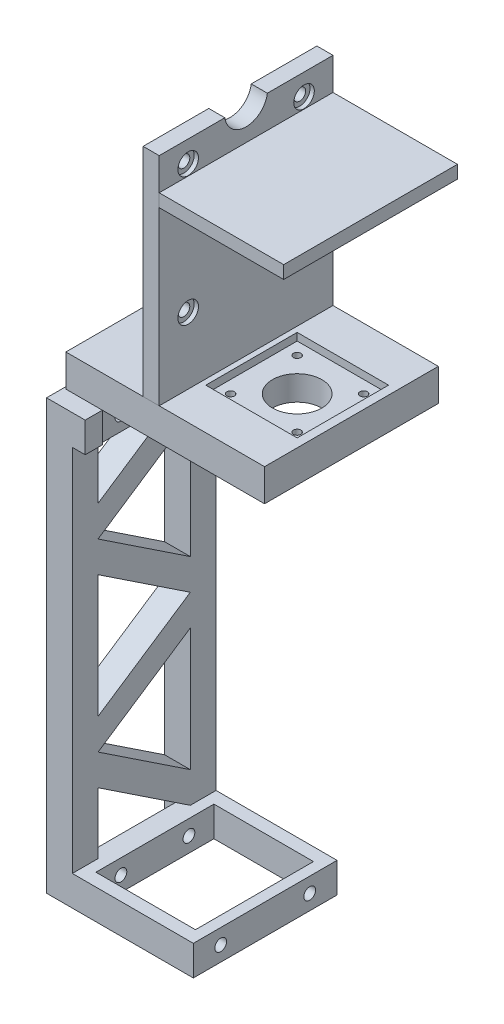
from build123d import *

# Parameters (mm, degrees)
SKETCH1_W            = 56.4
SKETCH1_H            = 67
SKETCH1_W_2          = 46.4
SKETCH1_H_2          = 55
BOSS_EXTRUDE1_DEPTH  = 14
SKETCH4_W            = 12
SKETCH4_H            = 12
BOSS_EXTRUDE2_DEPTH  = 200
SKETCH16_W           = 4.6
SKETCH16_H           = 14
BOSS_EXTRUDE11_DEPTH = 43
SKETCH5_W            = 5
SKETCH5_H            = 67
BOSS_EXTRUDE3_DEPTH  = 14
BOSS_EXTRUDE4_REACH  = 216.011
SKETCH2_R            = 2.75
CUT_EXTRUDE1_DEPTH   = 5
SKETCH3_R            = 2.75
CUT_EXTRUDE2_DEPTH   = 210.198972273
SKETCH7_R            = 2.75
CUT_EXTRUDE3_DEPTH   = 217.851100989
SKETCH8_W            = 8
SKETCH8_H            = 14
BOSS_EXTRUDE5_DEPTH  = 1
SKETCH9_W            = 92.6
SKETCH9_H            = 81
SKETCH9_W_2          = 6.786539707
BOSS_EXTRUDE6_DEPTH  = 15
SKETCH10_W           = 42.6
SKETCH10_H           = 42.6
CUT_EXTRUDE4_DEPTH   = 3.5
SKETCH11_R           = 1.75
SKETCH11_R_2         = 11.5
CUT_EXTRUDE5_DEPTH   = 11.5
CUT_EXTRUDE6_START   = 8.5
SKETCH11_5_R         = 3
SKETCH11_5_R_2       = 1.75
SKETCH11_5_R_3       = 11.5
CUT_EXTRUDE6_DEPTH   = 3
SKETCH13_R           = 2.75
BOSS_EXTRUDE7_DEPTH  = 5.5
BOSS_EXTRUDE10_START = -5.5
SKETCH13_3_R         = 4.8
BOSS_EXTRUDE10_DEPTH = 2
SKETCH15_W           = 81
SKETCH15_H           = 6
BOSS_EXTRUDE9_DEPTH  = 58


with BuildPart() as part:
    # Sketch1 → Boss-Extrude1 (new body)
    with BuildSketch(Plane(origin=(0, 0, 0), x_dir=(1, 0, 0), z_dir=(0, 1, 0))):
        Rectangle(SKETCH1_W, SKETCH1_H)
        Rectangle(SKETCH1_W_2, SKETCH1_H_2, mode=Mode.SUBTRACT)
    extrude(amount=BOSS_EXTRUDE1_DEPTH)

    # Sketch4 → Boss-Extrude2 (add)
    with BuildSketch(Plane(origin=(0, 0, 0), x_dir=(1, 0, 0), z_dir=(0, 1, 0))):
        with Locations((-34.2, -27.5)):
            Rectangle(SKETCH4_W, SKETCH4_H)
        with Locations((-34.2, 27.5)):
            Rectangle(SKETCH4_W, SKETCH4_H)
    extrude(amount=BOSS_EXTRUDE2_DEPTH)

    # Sketch16 → Boss-Extrude11 (add)
    with BuildSketch(Plane.XY.offset(-21.5)):
        with Locations((-30.5, 7)):
            Rectangle(SKETCH16_W, SKETCH16_H)
    extrude(amount=BOSS_EXTRUDE11_DEPTH)

    # Sketch5 → Boss-Extrude3 (add)
    with BuildSketch(Plane(origin=(0, 200, 0), x_dir=(1, 0, 0), z_dir=(0, 1, 0))):
        with Locations((-25.7, 0)):
            Rectangle(SKETCH5_W, SKETCH5_H)
    extrude(amount=-BOSS_EXTRUDE3_DEPTH)

    # Boss-Extrude4: up to this face of the body (flat: up to its plane)
    boss_extrude4_end = Plane(part.part.faces().sort_by_distance((-28.2, 100, 27.5))[0])
    # Sketch6 → Boss-Extrude4 (add, up to the picked face)
    with BuildSketch(Plane.ZY.offset(40.2), mode=Mode.PRIVATE) as boss_extrude4_sk1:
        Polygon((21.5, 157.410301507), (-21.5, 186), (-21.5, 171.589698493), (21.5, 143), align=None)
    boss_extrude4_tool1 = split(extrude(boss_extrude4_sk1.sketch, amount=-BOSS_EXTRUDE4_REACH, mode=Mode.PRIVATE), bisect_by=boss_extrude4_end, keep=Keep.BOTH, mode=Mode.PRIVATE)
    # Sketch6 → Boss-Extrude4 (add, up to the picked face)
    with BuildSketch(Plane.ZY.offset(40.2), mode=Mode.PRIVATE) as boss_extrude4_sk2:
        Polygon((21.5, 128.589698493), (21.5, 143), (-21.5, 114.410301507), (-21.5, 100), align=None)
    boss_extrude4_tool2 = split(extrude(boss_extrude4_sk2.sketch, amount=-BOSS_EXTRUDE4_REACH, mode=Mode.PRIVATE), bisect_by=boss_extrude4_end, keep=Keep.BOTH, mode=Mode.PRIVATE)
    # Sketch6 → Boss-Extrude4 (add, up to the picked face)
    with BuildSketch(Plane.ZY.offset(40.2), mode=Mode.PRIVATE) as boss_extrude4_sk3:
        Polygon((21.5, 71.410301507), (-21.5, 100), (-21.5, 85.589698493), (21.5, 57), align=None)
    boss_extrude4_tool3 = split(extrude(boss_extrude4_sk3.sketch, amount=-BOSS_EXTRUDE4_REACH, mode=Mode.PRIVATE), bisect_by=boss_extrude4_end, keep=Keep.BOTH, mode=Mode.PRIVATE)
    # Sketch6 → Boss-Extrude4 (add, up to the picked face)
    with BuildSketch(Plane.ZY.offset(40.2), mode=Mode.PRIVATE) as boss_extrude4_sk4:
        Polygon((21.5, 42.589698493), (21.5, 57), (-21.5, 28.410301507), (-21.5, 14), align=None)
    boss_extrude4_tool4 = split(extrude(boss_extrude4_sk4.sketch, amount=-BOSS_EXTRUDE4_REACH, mode=Mode.PRIVATE), bisect_by=boss_extrude4_end, keep=Keep.BOTH, mode=Mode.PRIVATE)
    add(boss_extrude4_tool1.solids().sort_by(Axis((-40.2, 164.5, 0), (1, 0, 0)))[0])
    add(boss_extrude4_tool2.solids().sort_by(Axis((-40.2, 121.5, 0), (1, 0, 0)))[0])
    add(boss_extrude4_tool3.solids().sort_by(Axis((-40.2, 78.5, 0), (1, 0, 0)))[0])
    add(boss_extrude4_tool4.solids().sort_by(Axis((-40.2, 35.5, 0), (1, 0, 0)))[0])

    # Sketch2 → Cut-Extrude1 (cut)
    with BuildSketch(Plane(origin=(28.2, 0, 0), x_dir=(0, 0, -1), z_dir=(1, 0, 0))):
        with Locations((-20.75, 7)):
            Circle(SKETCH2_R)
        with Locations((20.75, 7)):
            Circle(SKETCH2_R)
    extrude(amount=-CUT_EXTRUDE1_DEPTH, mode=Mode.SUBTRACT)

    # Sketch3 → Cut-Extrude2 (cut, through all)
    with BuildSketch(Plane(origin=(-23.2, 0, 0), x_dir=(0, 0, -1), z_dir=(1, 0, 0))):
        with Locations((15.85, 7)):
            Circle(SKETCH3_R)
        with Locations((-15.85, 7)):
            Circle(SKETCH3_R)
    extrude(amount=-CUT_EXTRUDE2_DEPTH, mode=Mode.SUBTRACT)

    # Sketch7 → Cut-Extrude3 (cut, through all)
    with BuildSketch(Plane(origin=(-23.2, 0, -32.7), x_dir=(0, 0, -1), z_dir=(1, 0, 0))):
        with Locations((-16.85, 193)):
            Circle(SKETCH7_R)
        with Locations((-48.55, 193)):
            Circle(SKETCH7_R)
    extrude(amount=-CUT_EXTRUDE3_DEPTH, mode=Mode.SUBTRACT)

    # Sketch8 → Boss-Extrude5 (add)
    with BuildSketch(Plane(origin=(-23.2, 0, 0), x_dir=(0, 0, -1), z_dir=(1, 0, 0))):
        with Locations((-29.5, 193)):
            Rectangle(SKETCH8_W, SKETCH8_H)
        with Locations((29.5, 193)):
            Rectangle(SKETCH8_W, SKETCH8_H)
    extrude(amount=BOSS_EXTRUDE5_DEPTH)


with BuildPart() as body_2:
    # Sketch9 → Boss-Extrude6 (new body)
    with BuildSketch(Plane(origin=(0, 215, 0), x_dir=(1, 0, 0), z_dir=(0, 1, 0))):
        with Locations((22.1, 0)):
            Rectangle(SKETCH9_W, SKETCH9_H)
        with Locations((-18.806730147, 0)):
            Rectangle(SKETCH9_W_2, SKETCH9_H)
    extrude(amount=BOSS_EXTRUDE6_DEPTH)

    # Sketch10 → Cut-Extrude4 (cut)
    with BuildSketch(Plane(origin=(0, 230, 0), x_dir=(1, 0, 0), z_dir=(0, 1, 0))):
        with Locations((43.1, 0)):
            Rectangle(SKETCH10_W, SKETCH10_H)
    extrude(amount=-CUT_EXTRUDE4_DEPTH, mode=Mode.SUBTRACT)

    # Sketch11 → Cut-Extrude5 (cut)
    with BuildSketch(Plane(origin=(0, 226.5, -221.5), x_dir=(1, 0, 0), z_dir=(0, -1, 0))):
        with Locations(Location((58.6, 237, 0), (0, 0, 90))):
            Circle(SKETCH11_R)
        with Locations(Location((27.6, 237, 0), (0, 0, 90))):
            Circle(SKETCH11_R)
        with Locations(Location((27.6, 206, 0), (0, 0, 90))):
            Circle(SKETCH11_R)
        with Locations(Location((58.6, 206, 0), (0, 0, 90))):
            Circle(SKETCH11_R)
        with Locations(Location((43.1, 221.5, 0), (0, 0, 90))):
            Circle(SKETCH11_R_2)
    extrude(amount=CUT_EXTRUDE5_DEPTH, mode=Mode.SUBTRACT)

    # Sketch11_5 → Cut-Extrude6 (cut)
    with BuildSketch(Plane(origin=(0, 226.5, -221.5), x_dir=(1, 0, 0), z_dir=(0, -1, 0)).offset(CUT_EXTRUDE6_START)):
        with Locations(Location((27.6, 237, 0), (0, 0, 90))):
            Circle(SKETCH11_5_R)
        with Locations(Location((27.6, 237, 0), (0, 0, 90))):
            Circle(SKETCH11_5_R_2, mode=Mode.SUBTRACT)
        with Locations(Location((58.6, 237, 0), (0, 0, 90))):
            Circle(SKETCH11_5_R)
        with Locations(Location((58.6, 237, 0), (0, 0, 90))):
            Circle(SKETCH11_5_R_2, mode=Mode.SUBTRACT)
        with Locations(Location((58.6, 206, 0), (0, 0, 90))):
            Circle(SKETCH11_5_R)
        with Locations(Location((58.6, 206, 0), (0, 0, 90))):
            Circle(SKETCH11_5_R_2, mode=Mode.SUBTRACT)
        with Locations(Location((27.6, 206, 0), (0, 0, 90))):
            Circle(SKETCH11_5_R)
        with Locations(Location((27.6, 206, 0), (0, 0, 90))):
            Circle(SKETCH11_5_R_2, mode=Mode.SUBTRACT)
        with Locations(Location((43.1, 221.5, 0), (0, 0, 90))):
            Circle(SKETCH11_5_R_3)
    extrude(amount=CUT_EXTRUDE6_DEPTH, mode=Mode.SUBTRACT)


with BuildPart() as body_3:
    # Sketch13 → Boss-Extrude7 (new body)
    with BuildSketch(Plane.ZY.offset(-11.8)):
        with BuildLine():
            Line((-9.905396324, 331), (-40.5, 331))
            Line((-40.5, 331), (-40.5, 230))
            Line((-40.5, 230), (40.5, 230))
            Line((40.5, 230), (40.5, 331))
            Line((40.5, 331), (9.905396324, 331))
            ThreePointArc((9.905396324, 331), (0, 322.372269531), (-9.905396324, 331))
        make_face()
        with Locations((-27, 261)):
            Circle(SKETCH13_R, mode=Mode.SUBTRACT)
        with Locations((27, 321)):
            Circle(SKETCH13_R, mode=Mode.SUBTRACT)
        with Locations((27, 261)):
            Circle(SKETCH13_R, mode=Mode.SUBTRACT)
        with Locations((-27, 321)):
            Circle(SKETCH13_R, mode=Mode.SUBTRACT)
    extrude(amount=-BOSS_EXTRUDE7_DEPTH)

    # Sketch13_3 → Boss-Extrude10 (add)
    with BuildSketch(Plane.ZY.offset(-11.8).offset(BOSS_EXTRUDE10_START)):
        with BuildLine():
            Line((-9.905396324, 331), (-40.5, 331))
            Line((-40.5, 331), (-40.5, 230))
            Line((-40.5, 230), (40.5, 230))
            Line((40.5, 230), (40.5, 331))
            Line((40.5, 331), (9.905396324, 331))
            ThreePointArc((9.905396324, 331), (0, 322.372269531), (-9.905396324, 331))
        make_face()
        with Locations((-27, 261)):
            Circle(SKETCH13_3_R, mode=Mode.SUBTRACT)
        with Locations((27, 261)):
            Circle(SKETCH13_3_R, mode=Mode.SUBTRACT)
        with Locations((-27, 321)):
            Circle(SKETCH13_3_R, mode=Mode.SUBTRACT)
        with Locations((27, 321)):
            Circle(SKETCH13_3_R, mode=Mode.SUBTRACT)
    extrude(amount=-BOSS_EXTRUDE10_DEPTH)


with BuildPart() as body_4:
    # Sketch15 → Boss-Extrude9 (new body)
    with BuildSketch(Plane(origin=(19.3, 0, 0), x_dir=(0, 0, -1), z_dir=(1, 0, 0))):
        with Locations((0, 313)):
            Rectangle(SKETCH15_W, SKETCH15_H)
    extrude(amount=BOSS_EXTRUDE9_DEPTH)


solid = Compound([part.part, body_2.part, body_3.part, body_4.part])
